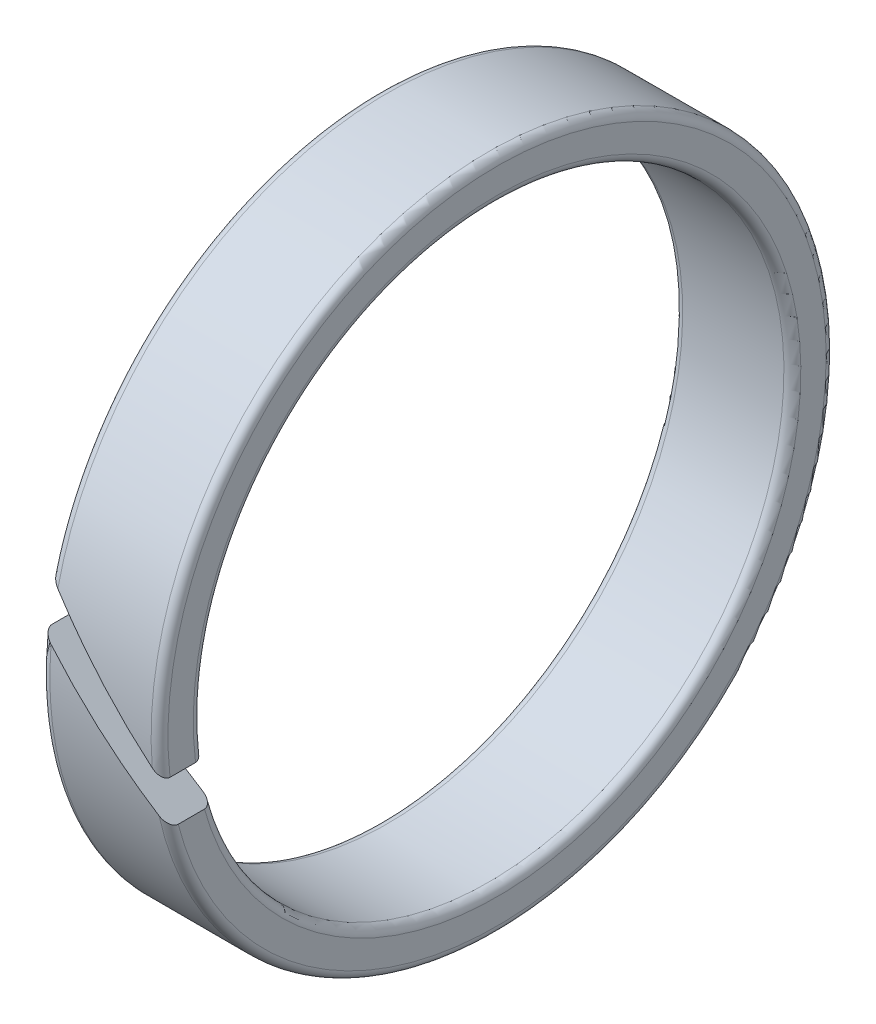
from build123d import *

# Parameters (mm, degrees)
SKETCH_1_W          = 5.6
SKETCH_1_H          = 2
CUT_EXTRUDE_1_DEPTH = 17
FILLET_1_R          = 0.4


with BuildPart() as part:
    # Эскиз1 → Повернуть1 (revolve)
    with BuildSketch(Plane.XY):
        with Locations((0, 15)):
            Rectangle(SKETCH_1_W, SKETCH_1_H)
    revolve(axis=Axis((0, 0, 0), (1, 0, 0)))

    # Эскиз2 → Вырез-Вытянуть1 (cut, through all)
    with BuildSketch(Plane.XY):
        Polygon((2.8, -3.860660172), (-3.860660172, 2.8), (-2.8, 3.860660172), (3.860660172, -2.8), align=None)
    extrude(amount=CUT_EXTRUDE_1_DEPTH, mode=Mode.SUBTRACT)

    # Скругление1
    fillet_1_edges = [part.edges().sort_by_distance(p)[0] for p in [
        (-2.8, -11.912796423, -10.681071172),
        (2.8, -9.854680037, -12.604970503),
        (-2.8, -10.496446008, -9.264157879),
        (2.8, -8.424688647, -11.181440927),
    ]]
    fillet(fillet_1_edges, radius=FILLET_1_R)


solid = part.part
